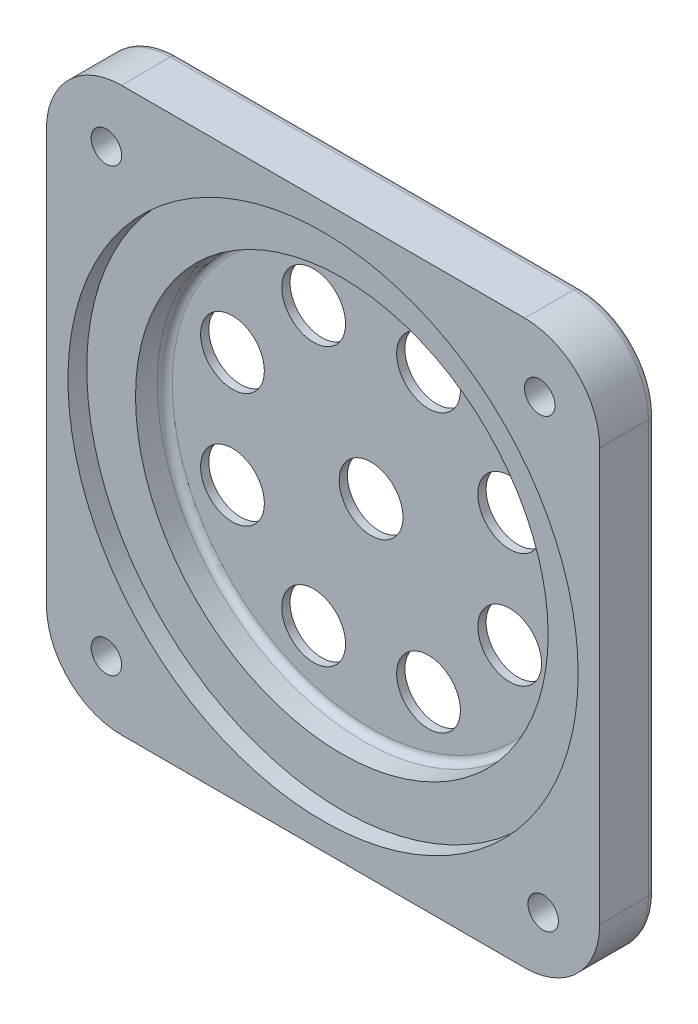
from build123d import *

# Parameters (mm, degrees)
BOSS_EXTRUDE1_DEPTH                          = 19.05
INSET_START                                  = 19.05
SKETCH4_R                                    = 86.36
INSET_RIM_DEPTH                              = 6.35
CUT_EXTRUDE1_START                           = 12.7
SKETCH9_R                                    = 69.85
CUT_EXTRUDE1_DEPTH                           = 6.35
CBORE_FOR_3_8_HEX_MACHINE_SCREW1_D           = 10.31748
CBORE_FOR_3_8_HEX_MACHINE_SCREW1_CBORE_D     = 22.225
CBORE_FOR_3_8_HEX_MACHINE_SCREW1_CBORE_DEPTH = 7.493
SKETCH12_R                                   = 10.795
CABLE_GLAND_OD_HOLES_DEPTH                   = 6.35
SKETCH13_R                                   = 69.85
CUT_EXTRUDE3_DEPTH                           = 3.556
FILLET1_R                                    = 2.54


with BuildPart() as part:
    # Sketch1 → Boss-Extrude1 (new body)
    with BuildSketch(Plane.XY):
        with BuildLine():
            Line((93.6625, 69.85), (93.6625, -69.85))
            ThreePointArc((93.6625, -69.85), (86.223012242, -87.810512242), (68.2625, -95.25))
            Line((68.2625, -95.25), (-68.2625, -95.25))
            ThreePointArc((-68.2625, -95.25), (-86.223012242, -87.810512242), (-93.6625, -69.85))
            Line((-93.6625, -69.85), (-93.6625, 69.85))
            ThreePointArc((-93.6625, 69.85), (-86.223012242, 87.810512242), (-68.2625, 95.25))
            Line((-68.2625, 95.25), (68.2625, 95.25))
            ThreePointArc((68.2625, 95.25), (86.223012242, 87.810512242), (93.6625, 69.85))
        make_face()
    extrude(amount=BOSS_EXTRUDE1_DEPTH)

    # Sketch4 → Inset Rim (cut)
    with BuildSketch(Plane.XY.offset(INSET_START)):
        Circle(SKETCH4_R)
    extrude(amount=-INSET_RIM_DEPTH, mode=Mode.SUBTRACT)

    # Sketch9 → Cut-Extrude1 (cut)
    with BuildSketch(Plane.XY.offset(CUT_EXTRUDE1_START)):
        Circle(SKETCH9_R)
    extrude(amount=-CUT_EXTRUDE1_DEPTH, mode=Mode.SUBTRACT)

    # CBORE for 3_8 Hex Machine Screw1 (through all)
    with Locations(Plane(origin=(0, 0, 0), x_dir=(-1, 0, 0), z_dir=(0, 0, -1))):
        with Locations((-74.521339476, -75.893393448), (-73.364603403, 74.715360062), (73.364603403, 74.715360062), (73.364603403, -74.715360062)):
            CounterBoreHole(CBORE_FOR_3_8_HEX_MACHINE_SCREW1_D / 2, CBORE_FOR_3_8_HEX_MACHINE_SCREW1_CBORE_D / 2, CBORE_FOR_3_8_HEX_MACHINE_SCREW1_CBORE_DEPTH)

    # Sketch12 → Cable Gland OD Holes (cut)
    with BuildSketch(Plane(origin=(0, 0, 0), x_dir=(-1, 0, 0), z_dir=(0, 0, -1))):
        Circle(SKETCH12_R)
        with Locations((19.440318364, 46.933080252)):
            Circle(SKETCH12_R)
        with Locations((46.933080827, 19.440319753)):
            Circle(SKETCH12_R)
        with Locations((46.933082215, -19.440316401)):
            Circle(SKETCH12_R)
        with Locations((19.440321716, -46.933078863)):
            Circle(SKETCH12_R)
        with Locations((-19.440314437, -46.933080252)):
            Circle(SKETCH12_R)
        with Locations((-46.9330769, -19.440319753)):
            Circle(SKETCH12_R)
        with Locations((-46.933078288, 19.440316401)):
            Circle(SKETCH12_R)
        with Locations((-19.440317789, 46.933078863)):
            Circle(SKETCH12_R)
    extrude(amount=-CABLE_GLAND_OD_HOLES_DEPTH, mode=Mode.SUBTRACT)

    # Sketch13 → Cut-Extrude3 (cut)
    with BuildSketch(Plane.XY.offset(6.35)):
        Circle(SKETCH13_R)
    extrude(amount=-CUT_EXTRUDE3_DEPTH, mode=Mode.SUBTRACT)

    # Fillet1
    fillet1_edges = [part.edges().sort_by_distance(p)[0] for p in [
        (93.6625, 0, 0),
        (86.223012242, -87.810512242, 0),
        (0, -95.25, 0),
        (-86.223012242, -87.810512242, 0),
        (-69.85, 0, 2.794),
        (-93.6625, 0, 0),
        (-86.223012242, 87.810512242, 0),
        (0, 95.25, 0),
        (86.223012242, 87.810512242, 0),
    ]]
    fillet(fillet1_edges, radius=FILLET1_R)


solid = part.part
